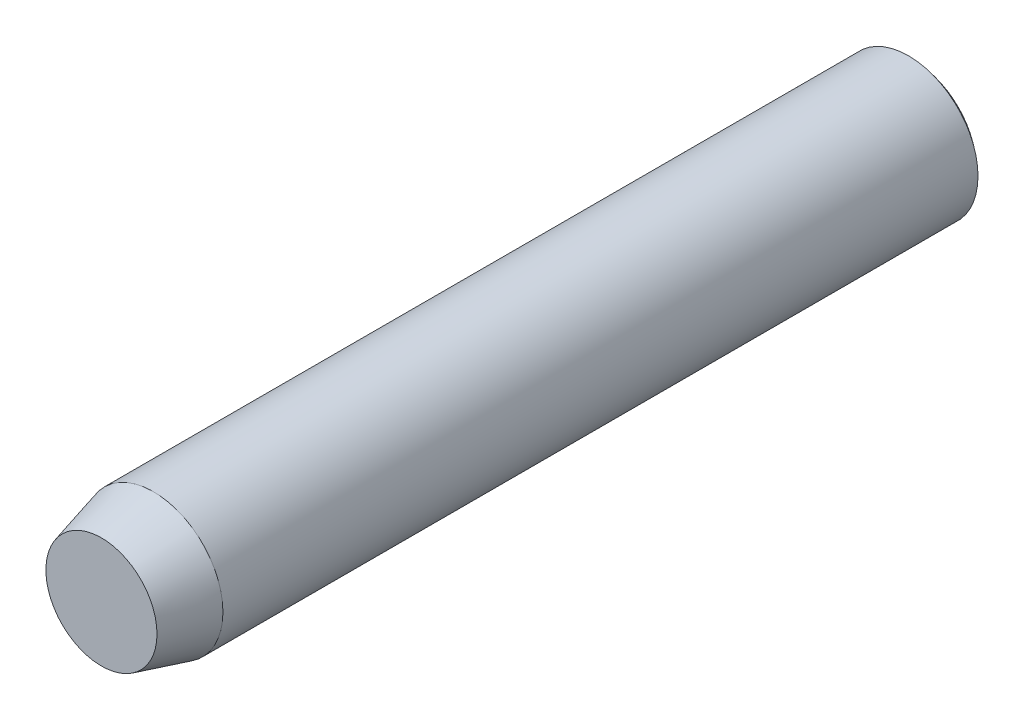
from build123d import *

# Parameters (mm, degrees)
CROQUIS1_R              = 2
SALIENTE_EXTRUIR1_DEPTH = 24
CHAFL_N1_SIZE           = 1.5
CHAFL_N1_SIZE2          = 0.4


with BuildPart() as part:
    # Croquis1 → Saliente-Extruir1 (new body)
    with BuildSketch(Plane.XY):
        Circle(CROQUIS1_R)
    extrude(amount=SALIENTE_EXTRUIR1_DEPTH)

    # Croquis2 → Cortar-Revolución3 (revolve, cut)
    with BuildSketch(Plane(origin=(0, 0, 0), x_dir=(1, 0, 0), z_dir=(0, 1, 0))):
        with BuildLine():
            Line((-2, -0.75), (-2, 0))
            Line((-2, 0), (-2, 0.2))
            Line((-2, 0.2), (0, 0.2))
            Line((0, 0.2), (0, 0))
            ThreePointArc((0, 0), (-1.068000468, -0.193665418), (-2, -0.75))
        make_face()
    revolve(axis=Axis((0, 0, 24), (0, 0, -1)), mode=Mode.SUBTRACT)

    # Chaflán1
    chafl_n1_edges = [part.edges().sort_by_distance(p)[0] for p in [
        (-2, 0, 24),
    ]]
    chafl_n1_side = [part.faces().sort_by_distance(p)[0] for p in [
        (-2, 0, 12.375),
    ]]
    chamfer(chafl_n1_edges, length=CHAFL_N1_SIZE, length2=CHAFL_N1_SIZE2, reference=chafl_n1_side[0])


solid = part.part
